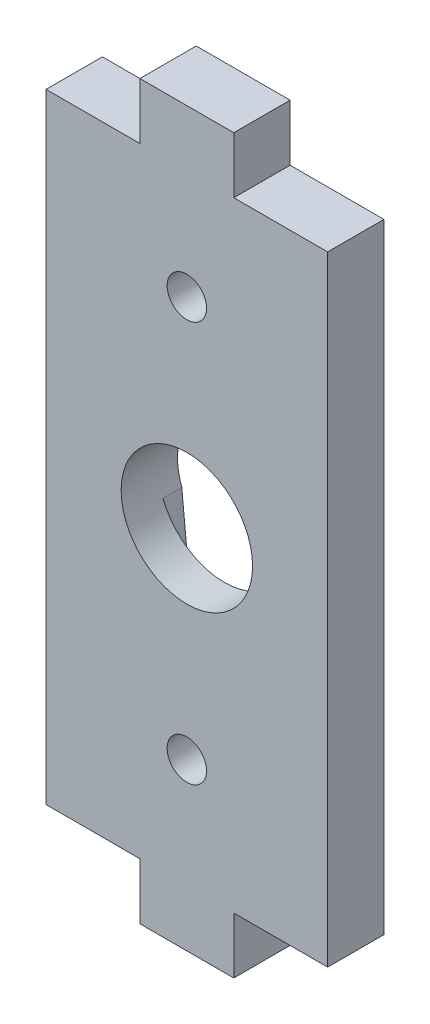
from build123d import *

# Parameters (mm, degrees)
CORTE_EXTERIOR_R        = 1.05
CORTE_EXTERIOR_R_2      = 3.5
SALIENTE_EXTRUIR1_DEPTH = 3
CORTAR_EXTRUIR1_DEPTH   = 1


with BuildPart() as part:
    # Corte exterior → Saliente-Extruir1 (new body)
    with BuildSketch(Plane.XY):
        Polygon((49.5, 10.5), (54.5, 10.5), (54.5, 13.5), (59.5, 13.5), (59.5, 29.5), (59.5, 46.5), (54.5, 46.5), (54.5, 49.5), (49.5, 49.5), (49.5, 46.5), (44.5, 46.5), (44.5, 23.5), (44.5, 13.5), (49.5, 13.5), align=None)
        with Locations((52, 40.672229454)):
            Circle(CORTE_EXTERIOR_R, mode=Mode.SUBTRACT)
        with Locations((52, 19.327770547)):
            Circle(CORTE_EXTERIOR_R, mode=Mode.SUBTRACT)
        with Locations((52, 30)):
            Circle(CORTE_EXTERIOR_R_2, mode=Mode.SUBTRACT)
    extrude(amount=SALIENTE_EXTRUIR1_DEPTH)

    # Grabado Superficie → Cortar-Extruir1 (cut)
    with BuildSketch(Plane.XY):
        with BuildLine():
            Line((48.730825792, 28.75), (50, 15.7))
            ThreePointArc((50, 15.7), (52, 13.7), (54, 15.7))
            Line((54, 15.7), (55.269174208, 28.75))
            ThreePointArc((55.269174208, 28.75), (52, 26.5), (48.730825792, 28.75))
        make_face()
        with BuildLine():
            Line((55.269174208, 31.25), (53.990313411, 44.196602453))
            ThreePointArc((53.990313411, 44.196602453), (51.901579532, 45.997576885), (50, 44))
            Line((50, 44), (48.730825792, 31.25))
            ThreePointArc((48.730825792, 31.25), (52, 33.5), (55.269174208, 31.25))
        make_face()
    extrude(amount=CORTAR_EXTRUIR1_DEPTH, mode=Mode.SUBTRACT)


solid = part.part
